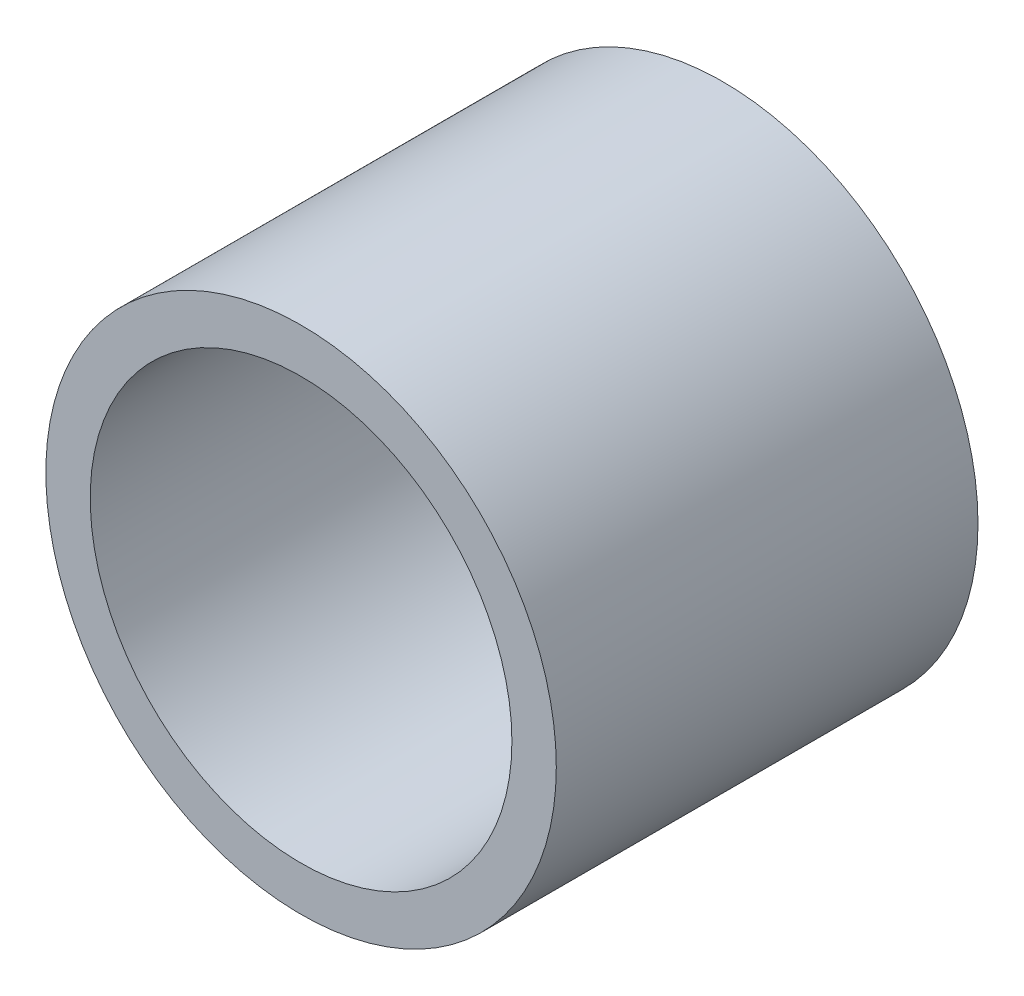
from build123d import *

# Parameters (mm, degrees)
CROQUIS1_R              = 11.5
CROQUIS1_R_2            = 9.5
SALIENTE_EXTRUIR1_DEPTH = 19


with BuildPart() as part:
    # Croquis1 → Saliente-Extruir1 (new body)
    with BuildSketch(Plane.XY):
        Circle(CROQUIS1_R)
        Circle(CROQUIS1_R_2, mode=Mode.SUBTRACT)
    extrude(amount=-SALIENTE_EXTRUIR1_DEPTH)


solid = part.part
